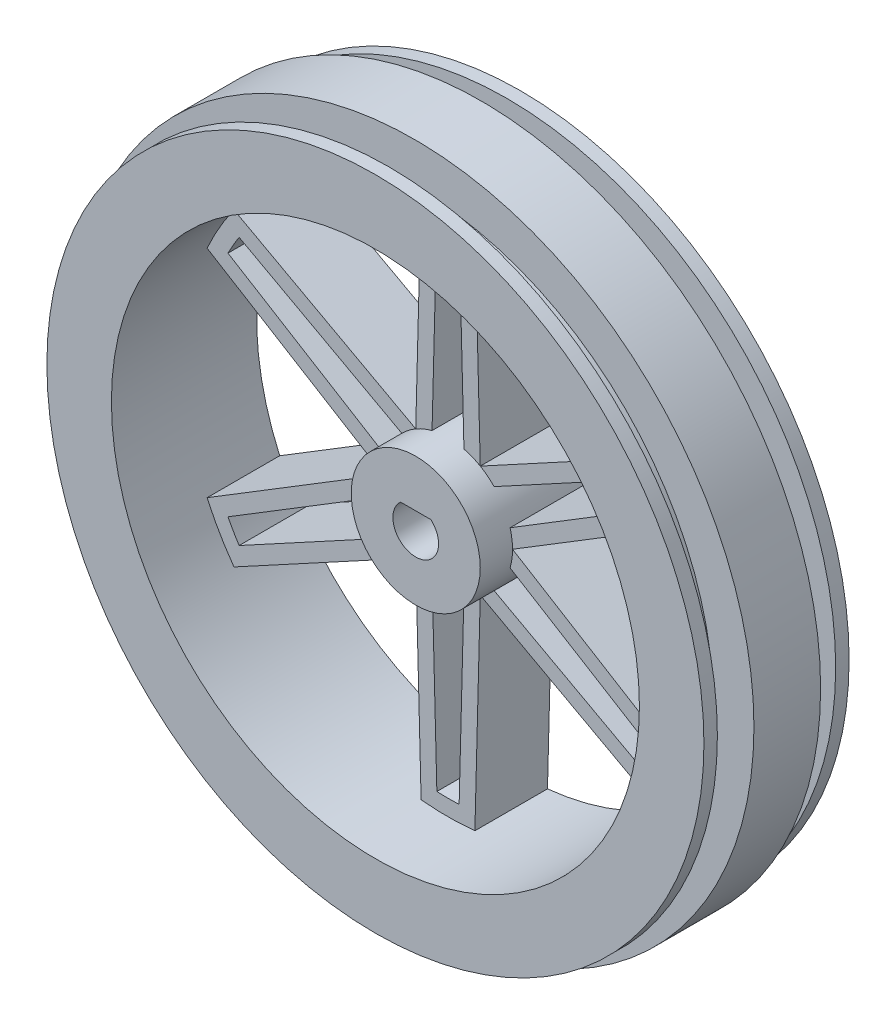
from build123d import *

# Parameters (mm, degrees)
SKETCH2_R         = 6
HUB_DEPTH         = 3
HUB_DEPTH_BACK    = 6.75
SPOKE_DEPTH       = 6.75
CIRPATTERN2_COUNT = 6


with BuildPart() as part:
    # Sketch1 → RIM (revolve)
    with BuildSketch(Plane(origin=(0, 0, 0), x_dir=(1, 0, 0), z_dir=(0, 1, 0))):
        Polygon((30.55, 6.75), (24.55, 6.75), (24.55, -6.75), (30.55, -6.75), (30.55, -5.5), (27.75, -5.5), (27.75, -3.1), (31.55, -3.1), (31.55, 3.1), (27.75, 3.1), (27.75, 5.5), (30.55, 5.5), align=None)
    revolve(axis=Axis((0, 0, 0), (0, 0, -1)))



with BuildPart() as body_2:
    # Sketch2 → HUB (new body, two sides)
    with BuildSketch(Plane.XY) as hub_sk:
        Circle(SKETCH2_R)
        with BuildLine():
            Line((-1.405555384, 1.59375), (1.405555384, 1.59375))
            ThreePointArc((1.405555384, 1.59375), (0, -2.125), (-1.405555384, 1.59375))
        make_face(mode=Mode.SUBTRACT)
    extrude(amount=HUB_DEPTH)
    extrude(hub_sk.sketch, amount=-HUB_DEPTH_BACK)


with BuildPart() as part_1:
    add(part.part)

    add(body_2.part)  # SPOKE merges body 2
    # Sketch3 → SPOKE (add)
    with BuildSketch(Plane.XY):
        with BuildLine():
            Line((-3, 5.196152423), (-2.5, 24.422377034))
            ThreePointArc((-2.5, 24.422377034), (0, 24.55), (2.5, 24.422377034))
            Line((2.5, 24.422377034), (3, 5.196152423))
            ThreePointArc((3, 5.196152423), (2.262883255, 5.556919954), (1.483432095, 5.813727653))
            Line((1.483432095, 5.813727653), (1.035788615, 23.026715831))
            ThreePointArc((1.035788615, 23.026715831), (0, 23.05), (-1.035788615, 23.026715831))
            Line((-1.035788615, 23.026715831), (-1.483432095, 5.813727653))
            ThreePointArc((-1.483432095, 5.813727653), (-2.262883255, 5.556919954), (-3, 5.196152423))
        make_face()
    spoke = extrude(amount=-SPOKE_DEPTH)

    # CirPattern2: SPOKE ×6 about axis
    cirpattern2_axis = Axis((0, 0, 0), (0, 0, 1))
    for i in range(1, CIRPATTERN2_COUNT):
        add(spoke.rotate(cirpattern2_axis, i * 360 / CIRPATTERN2_COUNT))


solid = part_1.part
